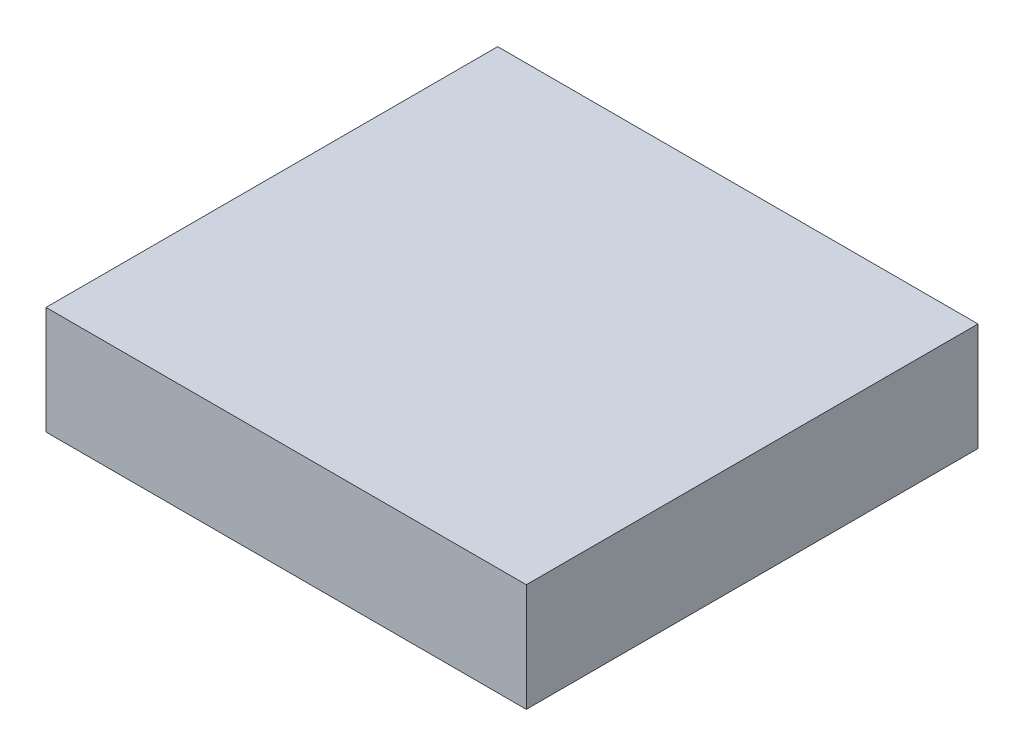
from build123d import *

# Parameters (mm, degrees)
SKETCH1_W           = 95.89
SKETCH1_H           = 90.17
BOSS_EXTRUDE1_DEPTH = 10.775


with BuildPart() as part:
    # Sketch1 → Boss-Extrude1 (new body, symmetric)
    with BuildSketch(Plane(origin=(0, 0, 0), x_dir=(1, 0, 0), z_dir=(0, 1, 0))):
        with Locations((0.05, 0)):
            Rectangle(SKETCH1_W, SKETCH1_H)
    extrude(amount=BOSS_EXTRUDE1_DEPTH, both=True)


solid = part.part
